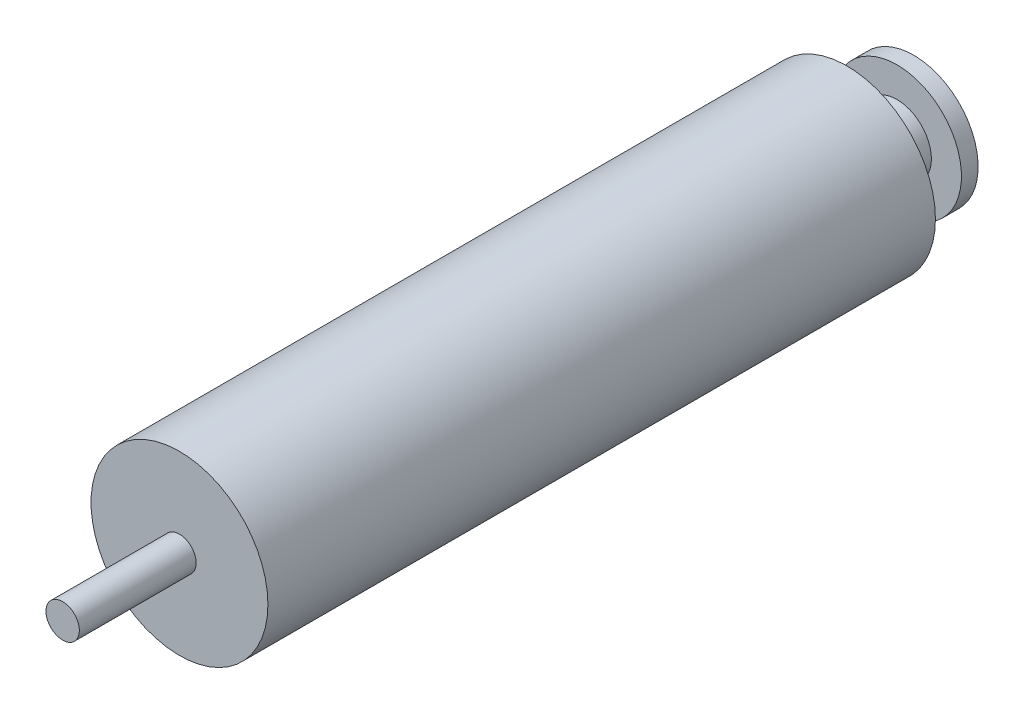
from build123d import *

# Parameters (mm, degrees)
SKETCH2_R           = 26.5
BOSS_EXTRUDE1_DEPTH = 200
SKETCH3_R           = 5
BOSS_EXTRUDE2_DEPTH = 35
SKETCH4_R           = 10.271360286
BOSS_EXTRUDE3_DEPTH = 15
SKETCH5_R           = 19.288260132
BOSS_EXTRUDE4_DEPTH = 5


with BuildPart() as part:
    # Sketch2 → Boss-Extrude1 (new body)
    with BuildSketch(Plane.XY):
        with Locations((29.69848481, 29.69848481)):
            Circle(SKETCH2_R)
    extrude(amount=BOSS_EXTRUDE1_DEPTH)

    # Sketch3 → Boss-Extrude2 (add)
    with BuildSketch(Plane.XY.offset(200)):
        with Locations((29.69848481, 29.69848481)):
            Circle(SKETCH3_R)
    extrude(amount=BOSS_EXTRUDE2_DEPTH)

    # Sketch4 → Boss-Extrude3 (add)
    with BuildSketch(Plane(origin=(0, 0, 0), x_dir=(-1, 0, 0), z_dir=(0, 0, -1))):
        with Locations((-29.69848481, 29.69848481)):
            Circle(SKETCH4_R)
    extrude(amount=BOSS_EXTRUDE3_DEPTH)

    # Sketch5 → Boss-Extrude4 (add)
    with BuildSketch(Plane(origin=(0, 0, -15), x_dir=(-1, 0, 0), z_dir=(0, 0, -1))):
        with Locations((-29.69848481, 29.69848481)):
            Circle(SKETCH5_R)
    extrude(amount=BOSS_EXTRUDE4_DEPTH)


solid = part.part
